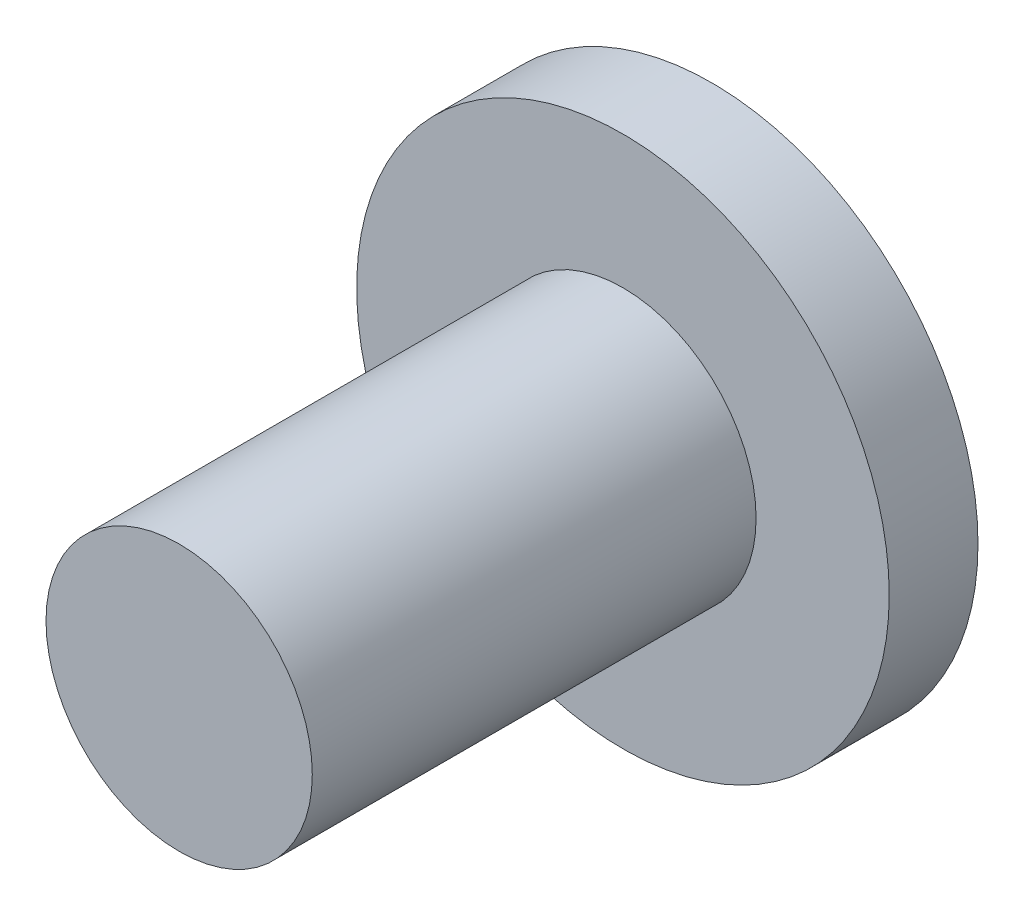
from build123d import *

# Parameters (mm, degrees)
SKETCH1_R           = 6
BOSS_EXTRUDE1_DEPTH = 2
SKETCH2_R           = 3
BOSS_EXTRUDE2_DEPTH = 10


with BuildPart() as part:
    # Sketch1 → Boss-Extrude1 (new body)
    with BuildSketch(Plane.XY):
        Circle(SKETCH1_R)
    extrude(amount=BOSS_EXTRUDE1_DEPTH)

    # Sketch2 → Boss-Extrude2 (add)
    with BuildSketch(Plane.XY.offset(2)):
        Circle(SKETCH2_R)
    extrude(amount=BOSS_EXTRUDE2_DEPTH)


solid = part.part
